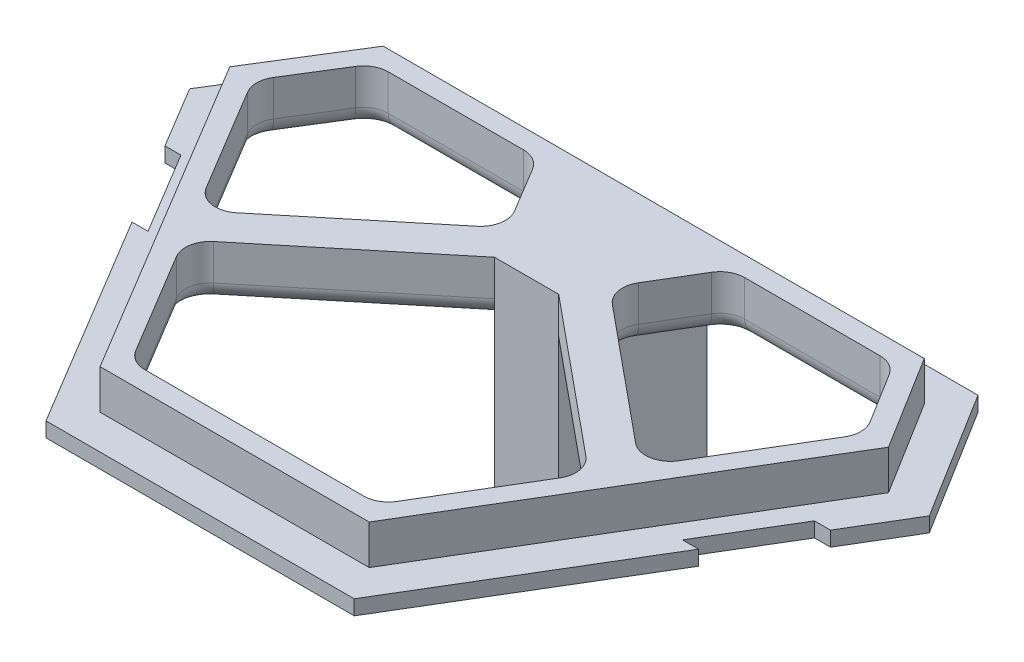
from build123d import *

# Parameters (mm, degrees)
BOSS_EXTRUDE1_DEPTH = 1.2
BOSS_EXTRUDE2_DEPTH = 4.2
SKETCH3_W           = 5.20563433
SKETCH3_H           = 12.0272654
BOSS_EXTRUDE3_DEPTH = 14
CHAMFER3_SIZE       = 1
SKETCH4_W           = 5.20563433
SKETCH4_H           = 8.716640791
BOSS_EXTRUDE4_DEPTH = 5.4
BOSS_EXTRUDE5_DEPTH = 5.4
BOSS_EXTRUDE8_DEPTH = 5.4
FILLET1_R           = 2
FILLET3_R           = 1.4835
SKETCH12_R          = 31.501357271
CUT_EXTRUDE1_DEPTH  = 1


with BuildPart() as part:
    # Sketch1 → Boss-Extrude1 (new body)
    with BuildSketch(Plane(origin=(0, 0, 0), x_dir=(1, 0, 0), z_dir=(0, 1, 0))):
        Polygon((12.5, -19.496991909), (22.977471756, -2.044517527), (21.677471756, -2.044517527), (25.692225392, 4.642914958), (26.992225392, 4.642914958), (30, 9.653008091), (23.5, 20.103008091), (-23.5, 20.103008091), (-30, 9.653008091), (-26.992225392, 4.642914958), (-25.692225392, 4.642914958), (-21.677471756, -2.044517527), (-22.977471756, -2.044517527), (-12.5, -19.496991909), align=None)
        Polygon((-21.05511414, 15.703008091), (21.05511414, 15.703008091), (24.843569396, 9.612337718), (10.009495006, -15.096991909), (-10.009495006, -15.096991909), (-24.843569396, 9.612337718), align=None, mode=Mode.SUBTRACT)
    extrude(amount=BOSS_EXTRUDE1_DEPTH)

    # Sketch2 → Boss-Extrude2 (add)
    with BuildSketch(Plane(origin=(0, 1.2, 0), x_dir=(1, 0, 0), z_dir=(0, 1, 0))):
        Polygon((26.71863507, 9.627126944), (21.944163543, 17.303008091), (-21.944163543, 17.303008091), (-26.71863507, 9.627126944), (-10.915133186, -16.696991909), (10.915133186, -16.696991909), align=None)
        Polygon((24.843569396, 9.612337718), (21.05511414, 15.703008091), (-21.05511414, 15.703008091), (-24.843569396, 9.612337718), (-10.009495006, -15.096991909), (10.009495006, -15.096991909), align=None, mode=Mode.SUBTRACT)
    extrude(amount=BOSS_EXTRUDE2_DEPTH)

    # Sketch3 → Boss-Extrude3 (add)
    with BuildSketch(Plane.XZ):
        with Locations((0, -13)):
            Rectangle(SKETCH3_W, SKETCH3_H)
    extrude(amount=BOSS_EXTRUDE3_DEPTH)

    # Chamfer3
    chamfer3_edges = [part.edges().sort_by_distance(p)[0] for p in [
        (0, 0, -19.0136327),
    ]]
    chamfer(chamfer3_edges, length=CHAMFER3_SIZE)

    # Sketch4 → Boss-Extrude4 (add)
    with BuildSketch(Plane(origin=(0, 0, 0), x_dir=(1, 0, 0), z_dir=(0, 1, 0))):
        with Locations((0, 11.344687696)):
            Rectangle(SKETCH4_W, SKETCH4_H)
    extrude(amount=BOSS_EXTRUDE4_DEPTH)

    # Sketch6 → Boss-Extrude5 (add)
    with BuildSketch(Plane(origin=(0, 5.4, 0), x_dir=(1, 0, 0), z_dir=(0, 1, 0))):
        Polygon((-7.835791911, 15.703008091), (-2.602817165, 6.9863673), (-2.602817165, 15.703008091), align=None)
    boss_extrude5 = extrude(amount=-BOSS_EXTRUDE5_DEPTH)

    # Mirror1: Boss-Extrude5 across plane
    add(boss_extrude5.mirror(Plane(origin=(0, 0, 0), x_dir=(0, 0, 1), z_dir=(1, 0, 0))))

    # Sketch10 → Boss-Extrude8 (add)
    with BuildSketch(Plane(origin=(0, 0, 0), x_dir=(-1, 0, 0), z_dir=(0, -1, 0))):
        Polygon((-2.602817165, 6.9863673), (-4.146953179, 9.558456717), (-17.976484501, -1.826263693), (-16.432348487, -4.398353111), align=None)
        Polygon((2.602817165, 6.9863673), (4.146953179, 9.558456717), (17.976484501, -1.826263693), (16.432348487, -4.398353111), align=None)
    extrude(amount=-BOSS_EXTRUDE8_DEPTH)

    # Fillet1
    fillet1_edges = [part.edges().sort_by_distance(p)[0] for p in [
        (-7.835791911, 2.7, -15.703008091),
        (7.835791911, 2.7, -15.703008091),
        (4.146953179, 2.7, -9.558456717),
        (17.976484501, 2.7, 1.826263693),
        (16.432348487, 2.7, 4.398353111),
        (-17.976484501, 2.7, 1.826263693),
        (-4.146953179, 2.7, -9.558456717),
        (-16.432348487, 2.7, 4.398353111),
        (10.009495006, 2.7, 15.096991909),
        (24.843569396, 2.7, -9.612337718),
        (21.05511414, 2.7, -15.703008091),
        (-21.05511414, 2.7, -15.703008091),
        (-24.843569396, 2.7, -9.612337718),
        (-10.009495006, 2.7, 15.096991909),
    ]]
    fillet(fillet1_edges, radius=FILLET1_R)

    # Fillet3
    fillet3_edges = [part.edges().sort_by_distance(p)[0] for p in [
        (-8.852151276, 0, -1.841802387),
        (-13.068628591, 0, 10.001349395),
        (13.068628591, 0, 10.001349395),
        (8.852151276, 0, -1.841802387),
        (0, 0, 15.096991909),
        (-14.45582101, 0, -15.703008091),
        (-22.920045025, 0, -12.704773052),
        (-21.692654112, 0, -4.363813116),
        (-10.831403301, 0, -4.055696431),
        (-6.143665701, 0, -12.88440929),
        (6.143665701, 0, -12.88440929),
        (14.45582101, 0, -15.703008091),
        (22.920045025, 0, -12.704773052),
        (21.692654112, 0, -4.363813116),
        (10.831403301, 0, -4.055696431),
        (-15.801291957, 0, 4.507128455),
        (15.801291957, 0, 4.507128455),
        (9.862625433, 0, 14.837515971),
        (-9.862625433, 0, 14.837515971),
        (-20.915222266, 0, -15.451248181),
        (-24.499675096, 0, -9.609625316),
        (-17.795848772, 0, 0.778311547),
        (-7.982661484, 0, -15.443532153),
        (7.982661484, 0, -15.443532153),
        (20.915222266, 0, -15.451248181),
        (24.499675096, 0, -9.609625316),
        (17.795848772, 0, 0.778311547),
        (4.778009709, 0, -9.667232062),
        (-4.778009709, 0, -9.667232062),
    ]]
    fillet(fillet3_edges, radius=FILLET3_R)

    # Sketch12 → Cut-Extrude1 (cut)
    with BuildSketch(Plane(origin=(0, 5.4, 0), x_dir=(1, 0, 0), z_dir=(0, 1, 0))):
        Circle(SKETCH12_R)
    extrude(amount=-CUT_EXTRUDE1_DEPTH, mode=Mode.SUBTRACT)


solid = part.part
